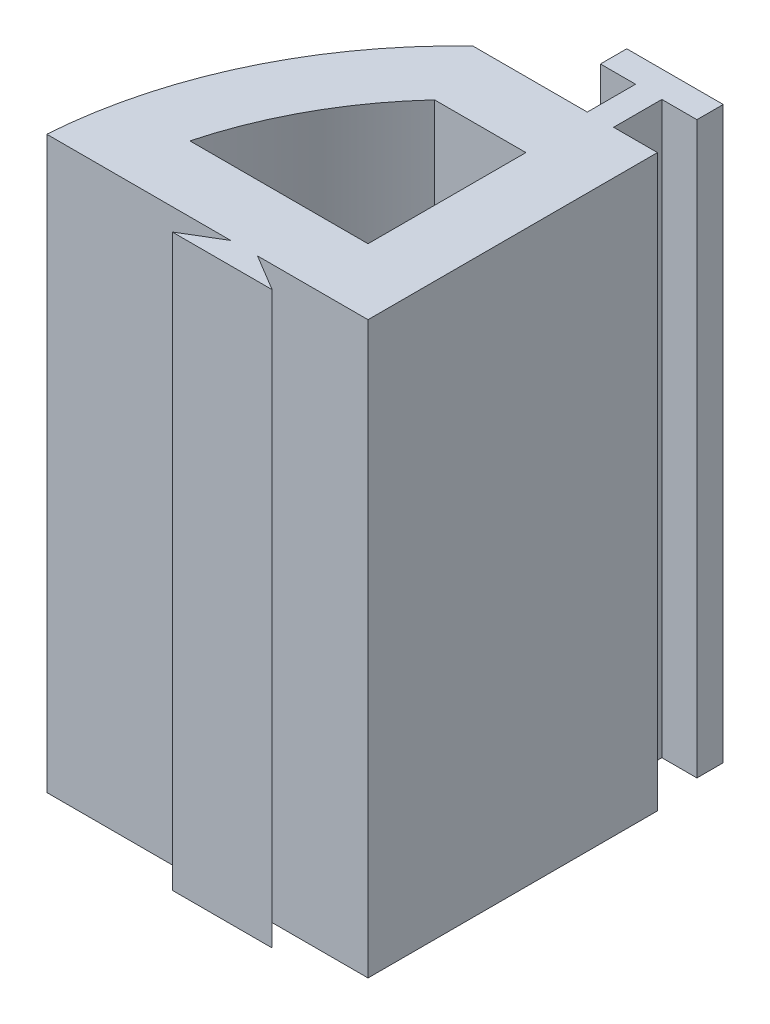
from build123d import *

# Parameters (mm, degrees)
SKETCH1_W           = 0.6
SKETCH1_H           = 0.2
BOSS_EXTRUDE1_DEPTH = 13
CUT_EXTRUDE1_DEPTH  = 14


with BuildPart() as part:
    # Sketch1 → Boss-Extrude1 (new body)
    with BuildSketch(Plane(origin=(0, 0, 0), x_dir=(1, 0, 0), z_dir=(0, 1, 0))):
        with BuildLine():
            Line((-2.7, 0.7), (-2.7, 7.3))
            Line((-2.7, 7.3), (-3.7, 7.3))
            Line((-3.7, 7.3), (-4.3, 7.3))
            Line((-4.3, 7.3), (-6.907423543, 7.3))
            ThreePointArc((-6.907423543, 7.3), (-9.08690024, 4.293104241), (-10.025592252, 0.7))
            Line((-10.025592252, 0.7), (-6.025, 0.7))
            Line((-6.025, 0.7), (-5.830634937, 0.7))
            Line((-5.830634937, 0.7), (-5.219365063, 0.7))
            Line((-5.219365063, 0.7), (-5.025, 0.7))
            Line((-5.025, 0.7), (-2.7, 0.7))
        make_face()
        Polygon((-5.076449576, 0.614250707), (-5.219365063, 0.7), (-5.830634937, 0.7), (-5.973550424, 0.614250707), (-6.16396827, 0.5), (-4.88603173, 0.5), align=None)
        Polygon((-4.576449576, 0.314250707), (-4.88603173, 0.5), (-6.16396827, 0.5), (-6.473550424, 0.314250707), (-6.66396827, 0.2), (-4.38603173, 0.2), align=None)
        with Locations((-4, 7.4)):
            Rectangle(SKETCH1_W, SKETCH1_H)
        with BuildLine():
            Line((-4.3, 7.5), (-3.7, 7.5))
            Line((-3.7, 7.5), (-3.7, 8.4))
            Line((-3.7, 8.4), (-2.9, 8.4))
            Line((-2.9, 8.4), (-2.9, 9))
            Line((-2.9, 9), (-4.472415455, 9))
            ThreePointArc((-4.472415455, 9), (-4.789229045, 8.835484432), (-5.1, 8.659821014))
            Line((-5.1, 8.659821014), (-5.1, 8.4))
            Line((-5.1, 8.4), (-4.3, 8.4))
            Line((-4.3, 8.4), (-4.3, 7.5))
        make_face()
        with BuildLine():
            Line((-5.1, 8.891147283), (-5.1, 8.659821014))
            ThreePointArc((-5.1, 8.659821014), (-4.789229045, 8.835484432), (-4.472415455, 9))
            Line((-4.472415455, 9), (-4.905354218, 9))
            ThreePointArc((-4.905354218, 9), (-5.002973164, 8.946103035), (-5.1, 8.891147283))
        make_face()
        with BuildLine():
            Line((-5.1, 9), (-5.1, 8.891147283))
            ThreePointArc((-5.1, 8.891147283), (-5.002973164, 8.946103035), (-4.905354218, 9))
            Line((-4.905354218, 9), (-5.1, 9))
        make_face()
    extrude(amount=BOSS_EXTRUDE1_DEPTH)

    # Sketch2 → Cut-Extrude1 (cut, through all)
    with BuildSketch(Plane(origin=(0, 13, 0), x_dir=(1, 0, 0), z_dir=(0, 1, 0))):
        with BuildLine():
            Line((-4.2, 5.8), (-6.281918497, 5.8))
            ThreePointArc((-6.281918497, 5.8), (-7.491475696, 4.120714974), (-8.262112321, 2.2))
            Line((-8.262112321, 2.2), (-4.2, 2.2))
            Line((-4.2, 2.2), (-4.2, 5.8))
        make_face()
    extrude(amount=-CUT_EXTRUDE1_DEPTH, mode=Mode.SUBTRACT)


solid = part.part
